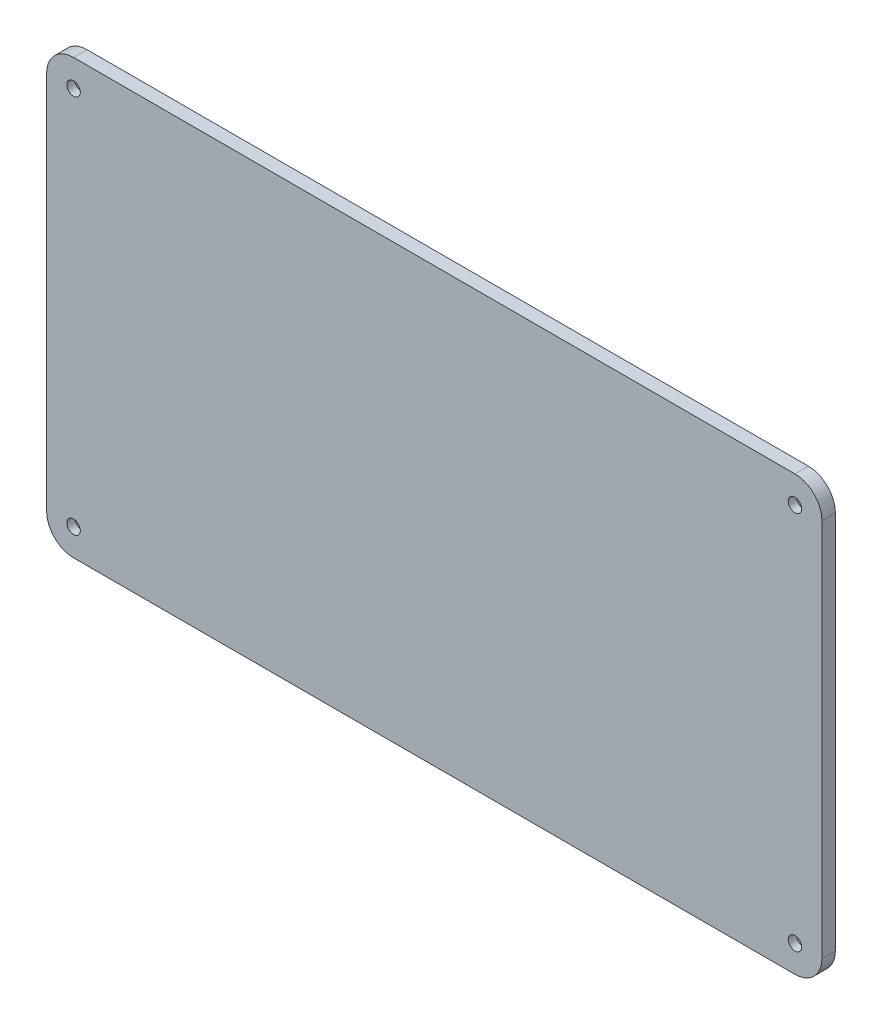
from build123d import *

# Parameters (mm, degrees)
BOSS_EXTRUDE1_DEPTH = 5
SKETCH2_R           = 0.8
CUT_EXTRUDE1_DEPTH  = 6
SKETCH3_R           = 2.5
CUT_EXTRUDE2_DEPTH  = 3


with BuildPart() as part:
    # Sketch1 → Boss-Extrude1 (new body)
    with BuildSketch(Plane.XY):
        with BuildLine():
            Line((10, 0), (278, 0))
            ThreePointArc((278, 0), (285.071067812, 2.928932188), (288, 10))
            Line((288, 10), (288, 151))
            ThreePointArc((288, 151), (285.071067812, 158.071067812), (278, 161))
            Line((278, 161), (10, 161))
            ThreePointArc((10, 161), (2.928932188, 158.071067812), (0, 151))
            Line((0, 151), (0, 10))
            ThreePointArc((0, 10), (2.928932188, 2.928932188), (10, 0))
        make_face()
    extrude(amount=BOSS_EXTRUDE1_DEPTH)

    # Sketch2 → Cut-Extrude1 (cut, through all)
    with BuildSketch(Plane.XY.offset(5)):
        with Locations((10, 151)):
            Circle(SKETCH2_R)
        with Locations((278, 151)):
            Circle(SKETCH2_R)
        with Locations((10, 10)):
            Circle(SKETCH2_R)
        with Locations((278, 10)):
            Circle(SKETCH2_R)
    extrude(amount=-CUT_EXTRUDE1_DEPTH, mode=Mode.SUBTRACT)

    # Sketch3 → Cut-Extrude2 (cut)
    with BuildSketch(Plane.XY.offset(5)):
        with Locations((10, 151)):
            Circle(SKETCH3_R)
        with Locations((10, 10)):
            Circle(SKETCH3_R)
        with Locations((278, 10)):
            Circle(SKETCH3_R)
        with Locations((278, 151)):
            Circle(SKETCH3_R)
    extrude(amount=-CUT_EXTRUDE2_DEPTH, mode=Mode.SUBTRACT)


solid = part.part
